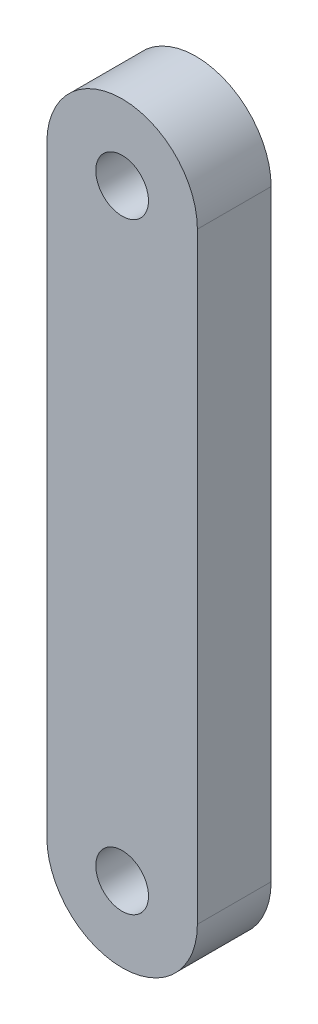
from build123d import *

# Parameters (mm, degrees)
SKETCH3_R           = 1.75
BOSS_EXTRUDE1_DEPTH = 4.9


with BuildPart() as part:
    # Sketch3 → Boss-Extrude1 (new body)
    with BuildSketch(Plane.XY):
        with BuildLine():
            Line((-4.978576916, 17.920910071), (-4.978576916, -22.079089929))
            ThreePointArc((-4.978576916, -22.079089929), (0.021423084, -27.079089929), (5.021423084, -22.079089929))
            Line((5.021423084, -22.079089929), (5.021423084, 17.920910071))
            ThreePointArc((5.021423084, 17.920910071), (0.021423084, 22.920910071), (-4.978576916, 17.920910071))
        make_face()
        with Locations((0.021423084, 17.920910071)):
            Circle(SKETCH3_R, mode=Mode.SUBTRACT)
        with Locations((0.021423084, -22.079089929)):
            Circle(SKETCH3_R, mode=Mode.SUBTRACT)
    extrude(amount=BOSS_EXTRUDE1_DEPTH)


solid = part.part
